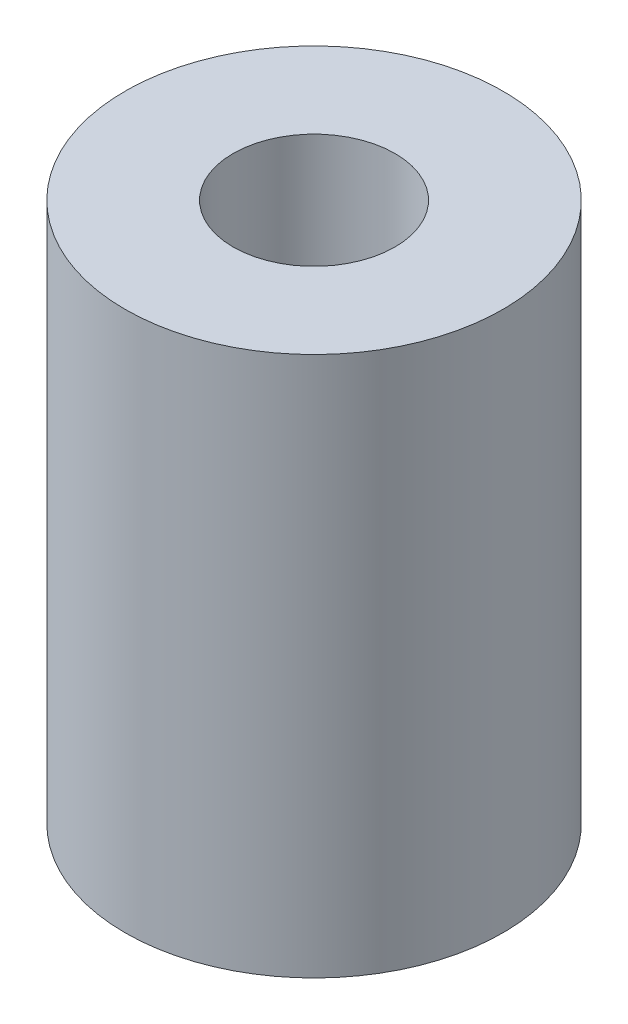
from build123d import *

# Parameters (mm, degrees)
SKETCH_1_R      = 3.5
SKETCH_1_R_2    = 1.5
EXTRUDE_1_DEPTH = 10


with BuildPart() as part:
    # 草图1 → 凸台-拉伸1 (new body)
    with BuildSketch(Plane(origin=(0, 0, 0), x_dir=(1, 0, 0), z_dir=(0, 1, 0))):
        Circle(SKETCH_1_R)
        Circle(SKETCH_1_R_2, mode=Mode.SUBTRACT)
    extrude(amount=EXTRUDE_1_DEPTH)


solid = part.part
